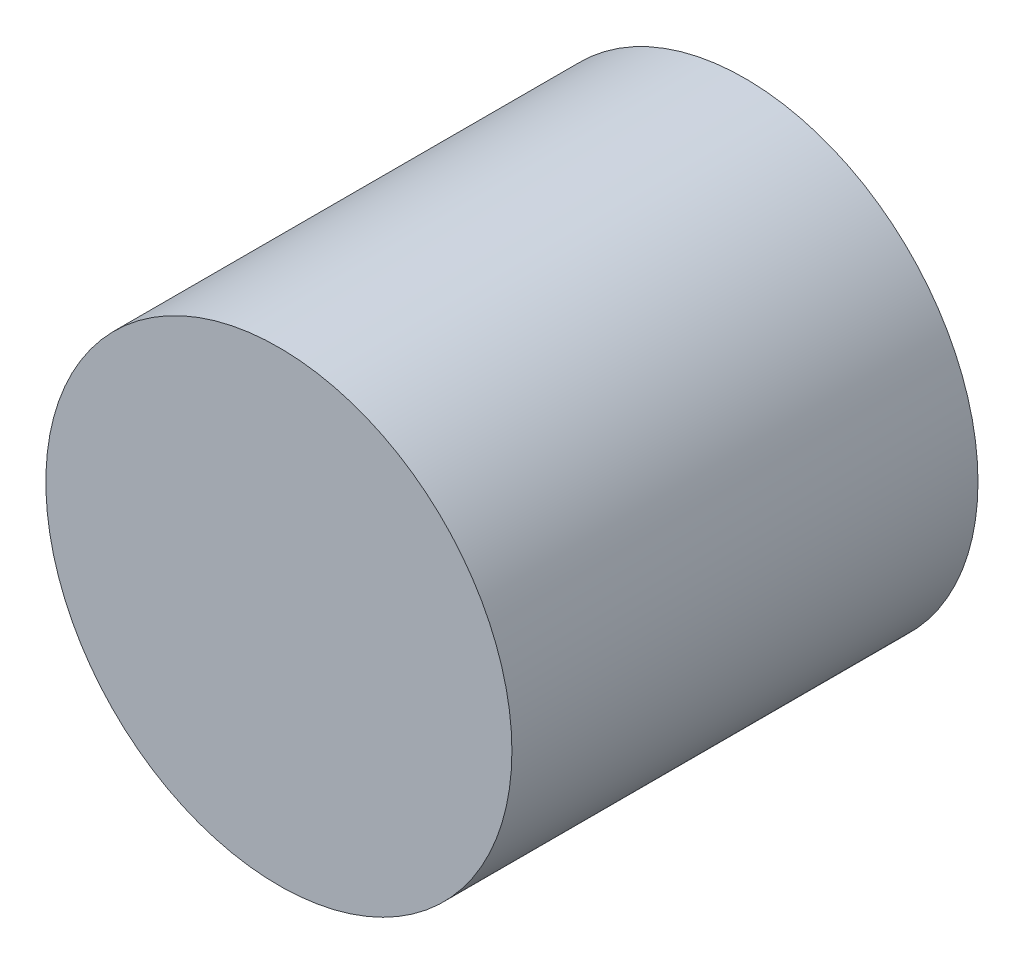
from build123d import *

# Parameters (mm, degrees)
SKIZZE4_R                            = 3
AUFSATZ_LINEAR_AUSTRAGEN1_DEPTH      = 3
AUFSATZ_LINEAR_AUSTRAGEN1_DEPTH_BACK = 3


with BuildPart() as part:
    # Skizze4 → Aufsatz-Linear austragen1 (new body, two sides)
    with BuildSketch(Plane.XY) as aufsatz_linear_austragen1_sk:
        with Locations((0, 680)):
            Circle(SKIZZE4_R)
    extrude(amount=AUFSATZ_LINEAR_AUSTRAGEN1_DEPTH)
    extrude(aufsatz_linear_austragen1_sk.sketch, amount=-AUFSATZ_LINEAR_AUSTRAGEN1_DEPTH_BACK)


solid = part.part
